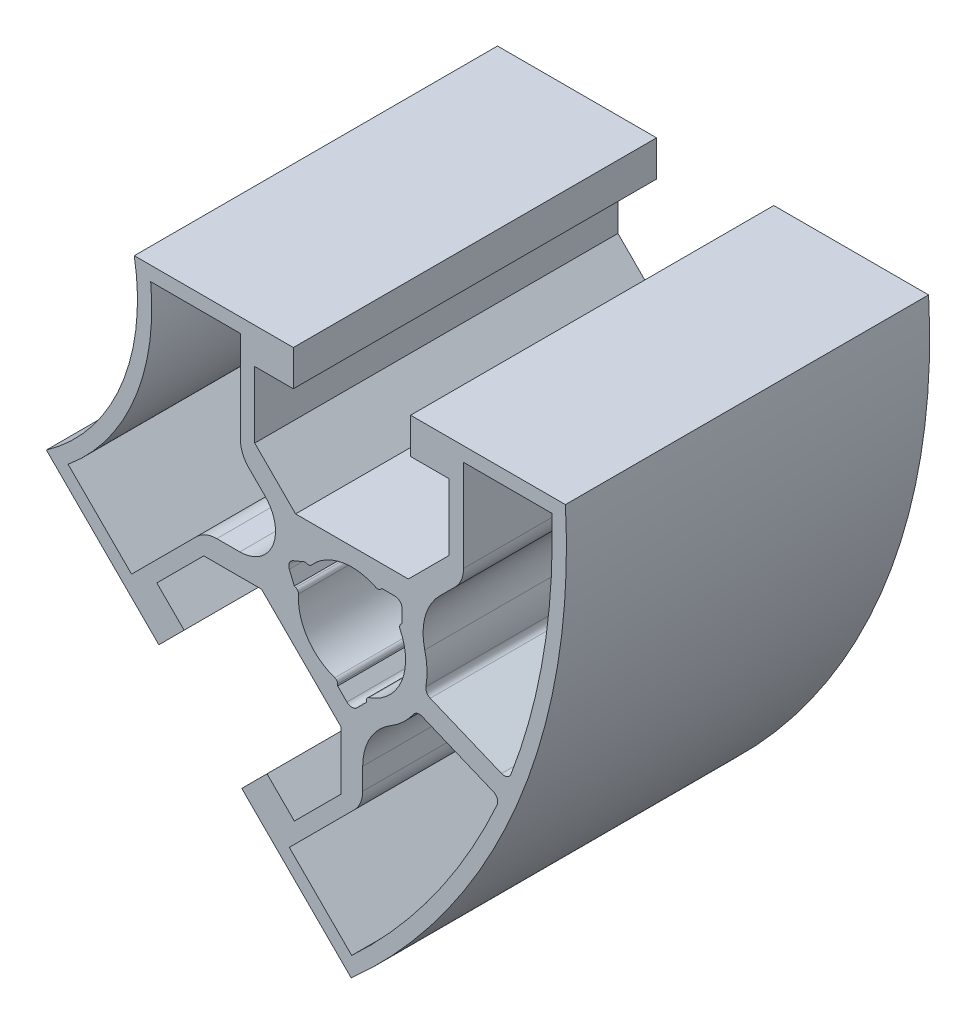
from build123d import *

# Parameters (mm, degrees)
EXTRUSION4_DEPTH = 25.4


with BuildPart() as part:
    # Sketch1 → Extrusion4 (new body)
    with BuildSketch(Plane.XY):
        with BuildLine():
            Line((-15.222428705, 14.999999974), (-4.099998637, 14.999999974))
            Line((-4.099998637, 14.999999974), (-4.099998631, 12.499999975))
            Line((-4.099998631, 12.499999975), (-6.799995581, 12.499999968))
            Line((-6.799995581, 12.499999968), (-6.79999557, 7.860655568))
            Line((-6.79999557, 7.860655568), (-3.941498133, 5.002158145))
            Line((-3.941498133, 5.002158145), (3.941497857, 5.002158165))
            Line((3.941497857, 5.002158165), (6.79999528, 7.860655602))
            Line((6.79999528, 7.860655602), (6.799995269, 12.500000002))
            Line((6.799995269, 12.500000002), (4.099998319, 12.499999995))
            Line((4.099998319, 12.499999995), (4.099998313, 14.999999995))
            Line((4.099998313, 14.999999995), (14.92634643, 15.000000022))
            ThreePointArc((14.92634643, 15.000000022), (14.981582716, 13.713730334), (14.999999839, 12.426406922))
            ThreePointArc((14.999999839, 12.426406922), (11.574578842, -4.794347555), (1.819805062, -19.393398286))
            ThreePointArc((1.819805062, -19.393398286), (0.896507077, -20.290650536), (-0.052080894, -21.161122609))
            Line((-0.052080894, -21.161122609), (-7.707465087, -13.505738454))
            Line((-7.707465087, -13.505738454), (-5.939698141, -11.7379715))
            Line((-5.939698141, -11.7379715), (-4.030511986, -13.647157645))
            Line((-4.030511986, -13.647157645), (-0.750000115, -10.366645757))
            Line((-0.750000115, -10.366645757), (-0.750000125, -6.324119927))
            Line((-0.750000125, -6.324119927), (-6.324120058, -0.75000002))
            Line((-6.324120058, -0.75000002), (-10.366645888, -0.75000003))
            Line((-10.366645888, -0.75000003), (-13.64715776, -4.030511919))
            Line((-13.64715776, -4.030511919), (-11.737971606, -5.939698064))
            Line((-11.737971606, -5.939698064), (-13.505738551, -7.707465018))
            Line((-13.505738551, -7.707465018), (-21.370484292, 0.157280684))
            ThreePointArc((-21.370484292, 0.157280684), (-20.34608634, 0.945903864), (-19.393398415, 1.819805117))
            ThreePointArc((-19.393398415, 1.819805117), (-16.141807163, 6.68615536), (-15.000000161, 12.426406848))
            ThreePointArc((-15.000000161, 12.426406848), (-15.055710753, 13.718000441), (-15.222428705, 14.999999974))
        make_face()
        with BuildLine():
            Line((-4.031774412, 0.587623385), (-4.381628794, 1.432246584))
            ThreePointArc((-4.381628794, 1.432246584), (-4.381628794, 1.814930015), (-4.111030745, 2.085528065))
            Line((-4.111030745, 2.085528065), (-3.266407566, 2.435382447))
            Line((-3.266407566, 2.435382447), (-3.161030076, 2.391733657))
            ThreePointArc((-3.161030076, 2.391733657), (-2.978032474, 2.376750688), (-2.820578756, 2.471201408))
            ThreePointArc((-2.820578756, 2.471201408), (-0.731588872, 3.677944803), (1.660186832, 3.362481109))
            ThreePointArc((1.660186832, 3.362481109), (1.841799821, 3.33547495), (2.005133821, 3.41934756))
            Line((2.005133821, 3.41934756), (2.085786261, 3.5))
            Line((2.085786261, 3.5), (2.999999821, 3.500000003))
            ThreePointArc((2.999999821, 3.500000003), (3.353553212, 3.353553393), (3.499999822, 3.000000004))
            Line((3.499999822, 3.000000004), (3.499999825, 2.085786444))
            Line((3.499999825, 2.085786444), (3.419347385, 2.005134004))
            ThreePointArc((3.419347385, 2.005134004), (3.335474775, 1.841800003), (3.362480936, 1.660187013))
            ThreePointArc((3.362480936, 1.660187013), (3.464548079, -1.435062852), (1.203703559, -3.551562652))
            ThreePointArc((1.203703559, -3.551562652), (1.056187548, -3.660886193), (0.999999859, -3.835687662))
            Line((0.999999859, -3.835687662), (0.99999986, -3.949747432))
            Line((0.99999986, -3.949747432), (0.353553251, -4.596194044))
            ThreePointArc((0.353553251, -4.596194044), (-1.38e-07, -4.742640655), (-0.353553529, -4.596194046))
            Line((-0.353553529, -4.596194046), (-1.00000014, -3.949747437))
            Line((-1.00000014, -3.949747437), (-1.000000141, -3.835687667))
            ThreePointArc((-1.000000141, -3.835687667), (-1.056187824, -3.660886194), (-1.203703841, -3.551562658))
            ThreePointArc((-1.203703841, -3.551562658), (-3.118011196, -2.083388382), (-3.741853671, 0.247046976))
            ThreePointArc((-3.741853671, 0.247046976), (-3.786403511, 0.425170315), (-3.926396922, 0.543974595))
            Line((-3.926396922, 0.543974595), (-4.031774412, 0.587623385))
        make_face(mode=Mode.SUBTRACT)
        with BuildLine():
            Line((7.799995261, 7.567762394), (7.799995245, 14.000000024))
            Line((7.799995245, 14.000000024), (13.971852229, 14.00000004))
            ThreePointArc((13.971852229, 14.00000004), (13.992962358, 13.213329344), (13.999999819, 12.426406924))
            ThreePointArc((13.999999819, 12.426406924), (13.273442442, 4.463419684), (11.117765058, -3.236587227))
            ThreePointArc((11.117765058, -3.236587227), (10.848477439, -3.517741288), (10.459176009, -3.520538429))
            Line((10.459176009, -3.520538429), (5.472273453, -1.454895771))
            ThreePointArc((5.472273453, -1.454895771), (5.225369073, -1.233664041), (5.171126882, -0.906612002))
            ThreePointArc((5.171126882, -0.906612002), (5.246544564, 0.190443263), (5.091786587, 1.279143428))
            ThreePointArc((5.091786587, 1.279143428), (5.115772732, 3.31925596), (6.142816007, 5.08215601))
            Line((6.142816007, 5.08215601), (7.214208825, 6.153548833))
            ThreePointArc((7.214208825, 6.153548833), (7.647754322, 6.802395532), (7.799995261, 7.567762394))
        make_face(mode=Mode.SUBTRACT)
        with BuildLine():
            Line((0.749999883, -9.452432163), (0.749999879, -7.937253913))
            ThreePointArc((0.749999879, -7.937253913), (1.270329188, -5.964466066), (2.695945821, -4.504927888))
            ThreePointArc((2.695945821, -4.504927888), (3.575203493, -3.84453103), (4.297610347, -3.01546746))
            ThreePointArc((4.297610347, -3.01546746), (4.567226078, -2.822561759), (4.898248297, -2.840715069))
            Line((4.898248297, -2.840715069), (9.885150852, -4.906357727))
            ThreePointArc((9.885150852, -4.906357727), (10.158450647, -5.183613277), (10.150059814, -5.57283431))
            ThreePointArc((10.150059814, -5.57283431), (6.229626845, -12.541855522), (1.112698256, -18.686291472))
            ThreePointArc((1.112698256, -18.686291472), (0.551283843, -19.237753416), (-0.019903451, -19.779086485))
            Line((-0.019903451, -19.779086485), (-4.384065382, -15.414924576))
            Line((-4.384065382, -15.414924576), (0.164213447, -10.866645724))
            ThreePointArc((0.164213447, -10.866645724), (0.597758953, -10.217799029), (0.749999883, -9.452432163))
        make_face(mode=Mode.SUBTRACT)
        with BuildLine():
            Line((-14.07756929, 13.99999997), (-7.799995595, 13.999999986))
            Line((-7.799995595, 13.999999986), (-7.799995579, 7.567762366))
            ThreePointArc((-7.799995579, 7.567762366), (-7.647754645, 6.802395501), (-7.214209135, 6.153548807))
            Line((-7.214209135, 6.153548807), (-6.078427273, 5.01776695))
            ThreePointArc((-6.078427273, 5.01776695), (-5.536495387, 2.29329142), (-7.846194212, 0.749999996))
            Line((-7.846194212, 0.749999996), (-9.452432322, 0.749999992))
            ThreePointArc((-9.452432322, 0.749999992), (-10.217799187, 0.597759058), (-10.866645881, 0.164213548))
            Line((-10.866645881, 0.164213548), (-15.414924709, -4.384065303))
            Line((-15.414924709, -4.384065303), (-19.853839651, 0.054849617))
            ThreePointArc((-19.853839651, 0.054849617), (-19.257037077, 0.569394344), (-18.686291624, 1.112698328))
            ThreePointArc((-18.686291624, 1.112698328), (-15.217927205, 6.303472924), (-14.000000151, 12.426409013))
            ThreePointArc((-14.000000151, 12.426409013), (-14.019404256, 13.214159839), (-14.07756929, 13.99999997))
        make_face(mode=Mode.SUBTRACT)
    extrude(amount=EXTRUSION4_DEPTH)


solid = part.part
